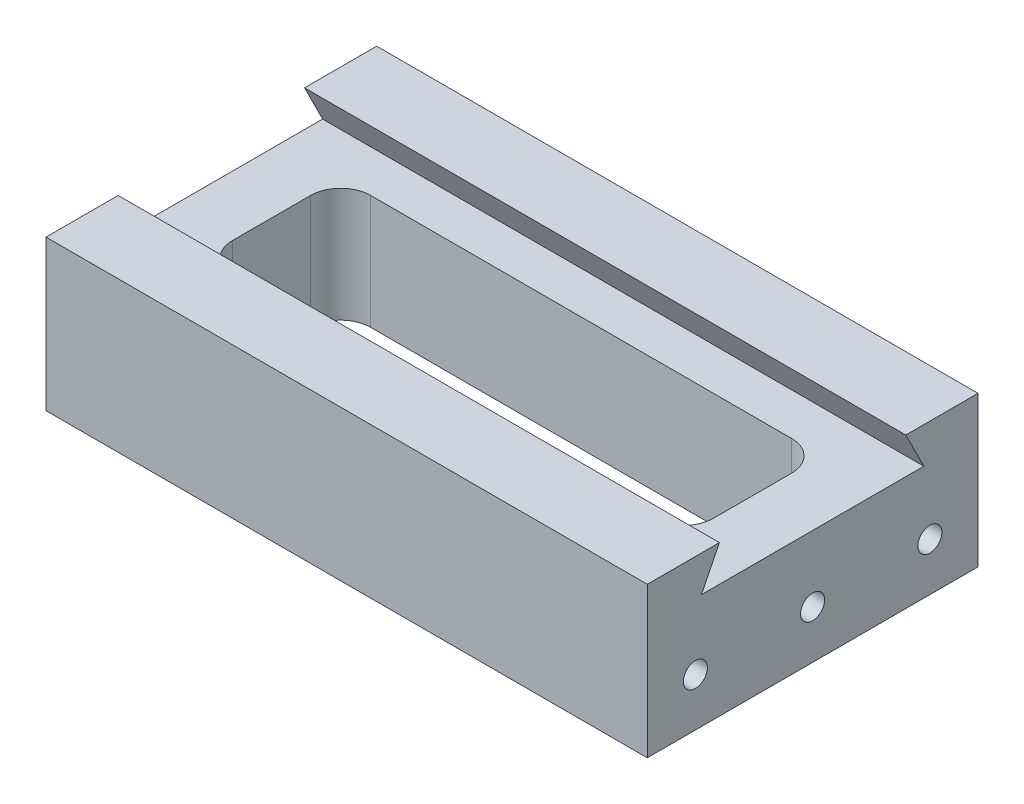
from build123d import *

# Parameters (mm, degrees)
BOSS_EXTRUDE1_DEPTH                  = 50
TAP_DRILL_FOR_M5X0_8_TAP1_AT_2_COUNT = 2
TAP_DRILL_FOR_M5X0_8_TAP1_AT_2_PITCH = 19.5
TAP_DRILL_FOR_M5X0_8_TAP1_AT_3_COUNT = 2
TAP_DRILL_FOR_M5X0_8_TAP1_AT_3_PITCH = 39
CUT_EXTRUDE1_DEPTH                   = 20


with BuildPart() as part:
    # Sketch1 → Boss-Extrude1 (new body, symmetric)
    with BuildSketch(Plane(origin=(0, 0, 0), x_dir=(0, 0, -1), z_dir=(1, 0, 0))):
        Polygon((9, 19), (46, 19), (43, 25), (55, 25), (55, 0), (0, 0), (0, 25), (12, 25), align=None)
    extrude(amount=BOSS_EXTRUDE1_DEPTH, both=True)

    # Sketch5 → Tap Drill for M5x0.8 Tap1 (revolve, cut)
    with BuildSketch(Plane(origin=(50, 8, -8), x_dir=(0, 0, -1), z_dir=(0, 1, 0))):
        Polygon((0, 0), (0, 8.401721238), (2, 7.2), (2, 0), align=None)
    tap_drill_for_m5x0_8_tap1 = revolve(axis=Axis((56.35, 8, -8), (-1, 0, 0)), mode=Mode.SUBTRACT)

    # Tap Drill for M5x0.8 Tap1 at 2: Tap Drill for M5x0.8 Tap1 ×2
    with Locations(*[(0, 0, -i * TAP_DRILL_FOR_M5X0_8_TAP1_AT_2_PITCH) for i in range(1, TAP_DRILL_FOR_M5X0_8_TAP1_AT_2_COUNT)]):
        add(tap_drill_for_m5x0_8_tap1, mode=Mode.SUBTRACT)

    # Tap Drill for M5x0.8 Tap1 at 3: Tap Drill for M5x0.8 Tap1 ×2
    with Locations(*[(0, 0, -i * TAP_DRILL_FOR_M5X0_8_TAP1_AT_3_PITCH) for i in range(1, TAP_DRILL_FOR_M5X0_8_TAP1_AT_3_COUNT)]):
        add(tap_drill_for_m5x0_8_tap1, mode=Mode.SUBTRACT)

    # Mirror2: Tap Drill for M5x0.8 Tap1 across plane
    add(tap_drill_for_m5x0_8_tap1.mirror(Plane(origin=(0, 0, 0), x_dir=(0, 0, 1), z_dir=(1, 0, 0))), mode=Mode.SUBTRACT)

    # Mirror2 copy 1 sketch → Mirror2 copy 1 (revolve, cut)
    with BuildSketch(Plane(origin=(-50, 8, -27.5), x_dir=(0, 0, -1), z_dir=(0, 1, 0))):
        Polygon((0, 0), (0, -8.401721238), (2, -7.2), (2, 0), align=None)
    revolve(axis=Axis((-56.35, 8, -27.5), (-1, 0, 0)), mode=Mode.SUBTRACT)

    # Mirror2 copy 2 sketch → Mirror2 copy 2 (revolve, cut)
    with BuildSketch(Plane(origin=(-50, 8, -47), x_dir=(0, 0, -1), z_dir=(0, 1, 0))):
        Polygon((0, 0), (0, -8.401721238), (2, -7.2), (2, 0), align=None)
    revolve(axis=Axis((-56.35, 8, -47), (-1, 0, 0)), mode=Mode.SUBTRACT)

    # Sketch6 → Cut-Extrude1 (cut, through all)
    with BuildSketch(Plane(origin=(0, 19, 0), x_dir=(1, 0, 0), z_dir=(0, 1, 0))):
        with BuildLine():
            Line((-35, 39), (35, 39))
            ThreePointArc((35, 39), (38.535533906, 37.535533906), (40, 34))
            Line((40, 34), (40, 21))
            ThreePointArc((40, 21), (38.535533906, 17.464466094), (35, 16))
            Line((35, 16), (-35, 16))
            ThreePointArc((-35, 16), (-38.535533906, 17.464466094), (-40, 21))
            Line((-40, 21), (-40, 34))
            ThreePointArc((-40, 34), (-38.535533906, 37.535533906), (-35, 39))
        make_face()
    extrude(amount=-CUT_EXTRUDE1_DEPTH, mode=Mode.SUBTRACT)


solid = part.part
